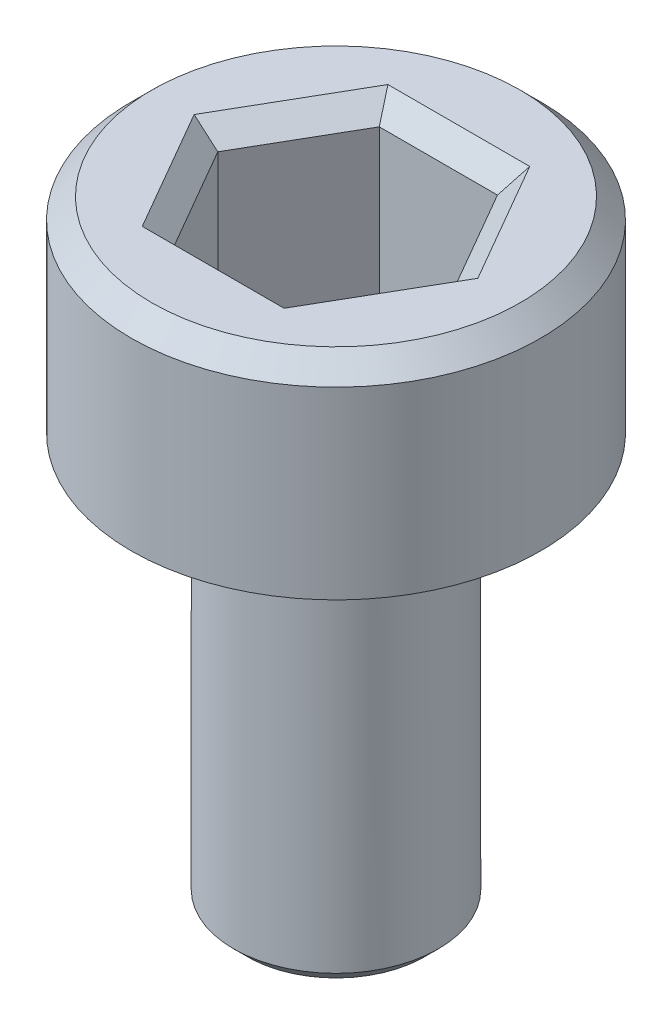
from build123d import *

# Parameters (mm, degrees)
SKETCH1_R           = 3
BOSS_EXTRUDE1_DEPTH = 3
CHAMFER1_SIZE       = 0.3
CUT_EXTRUDE1_DEPTH  = 2.5
CHAMFER2_SIZE       = 0.3
SKETCH3_R           = 1.5
BOSS_EXTRUDE2_DEPTH = 6
CHAMFER3_SIZE       = 0.2


with BuildPart() as part:
    # Sketch1 → Boss-Extrude1 (new body)
    with BuildSketch(Plane(origin=(0, 0, 0), x_dir=(1, 0, 0), z_dir=(0, 1, 0))):
        with Locations(Location((0, 0, 0), (0, 0, 270))):  # turned: the seam where the file's is
            Circle(SKETCH1_R)
    extrude(amount=BOSS_EXTRUDE1_DEPTH)

    # Chamfer1
    chamfer1_edges = [part.edges().sort_by_distance(p)[0] for p in [
        (0, 3, -3),
    ]]
    chamfer(chamfer1_edges, length=CHAMFER1_SIZE)

    # Sketch2 → Cut-Extrude1 (cut)
    with BuildSketch(Plane(origin=(0, 3, 0), x_dir=(1, 0, 0), z_dir=(0, 1, 0))):
        Polygon((1.732050808, 0), (0.866025404, 1.5), (-0.866025404, 1.5), (-1.732050808, 0), (-0.866025404, -1.5), (0.866025404, -1.5), align=None)
    extrude(amount=-CUT_EXTRUDE1_DEPTH, mode=Mode.SUBTRACT)

    # Chamfer2
    chamfer2_edges = [part.edges().sort_by_distance(p)[0] for p in [
        (1.299038106, 3, 0.75),
        (1.299038106, 3, -0.75),
        (0, 3, -1.5),
        (-1.299038106, 3, -0.75),
        (-1.299038106, 3, 0.75),
        (0, 3, 1.5),
    ]]
    chamfer(chamfer2_edges, length=CHAMFER2_SIZE)

    # Sketch3 → Boss-Extrude2 (add)
    with BuildSketch(Plane.XZ):
        with Locations(Location((0, 0, 0), (0, 0, 90))):  # turned: the seam where the file's is
            Circle(SKETCH3_R)
    extrude(amount=BOSS_EXTRUDE2_DEPTH)

    # Chamfer3
    chamfer3_edges = [part.edges().sort_by_distance(p)[0] for p in [
        (0, -6, -1.5),
    ]]
    chamfer(chamfer3_edges, length=CHAMFER3_SIZE)


solid = part.part
